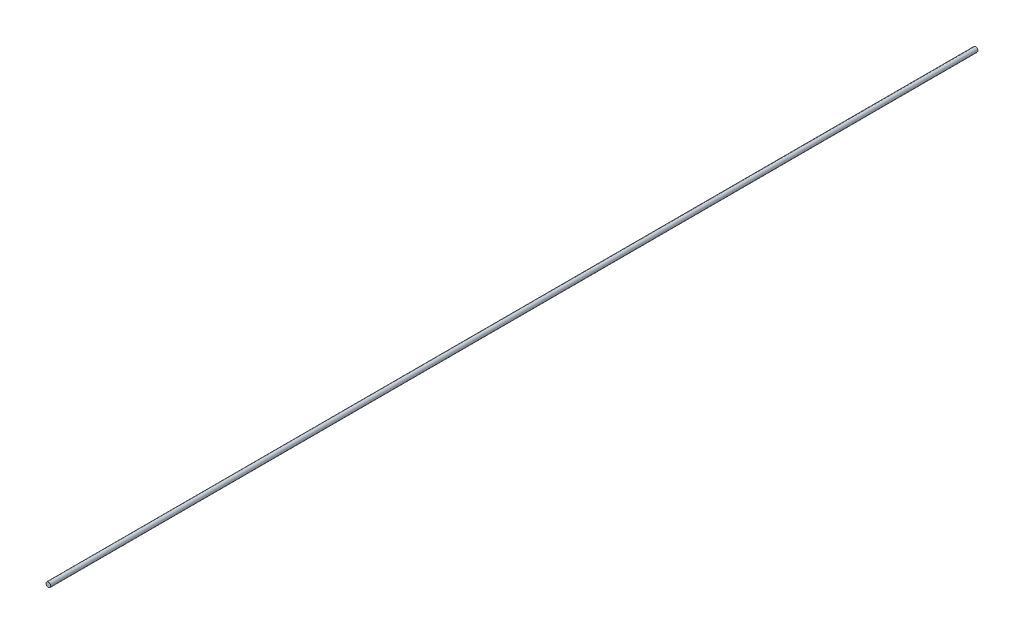
from build123d import *

# Parameters (mm, degrees)
ESQUISSE1_R        = 5
BOSS_EXTRU_1_DEPTH = 1980


with BuildPart() as part:
    # Esquisse1 → Boss.-Extru.1 (new body)
    with BuildSketch(Plane.XY):
        Circle(ESQUISSE1_R)
    extrude(amount=BOSS_EXTRU_1_DEPTH)


solid = part.part
